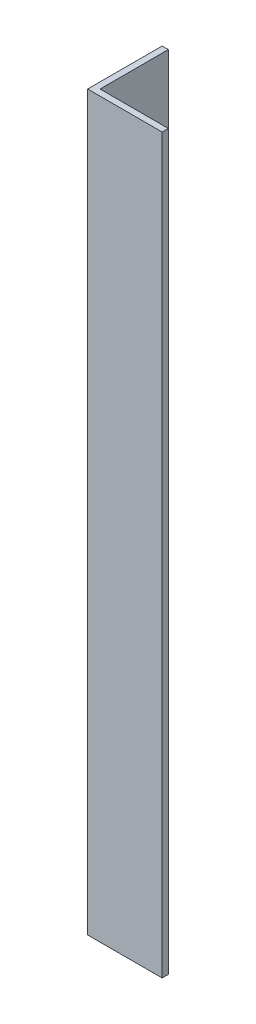
from build123d import *

# Parameters (mm, degrees)
BOSS_EXTRUDE1_DEPTH = 187.325


with BuildPart() as part:
    # Sketch1 → Boss-Extrude1 (new body)
    with BuildSketch(Plane(origin=(0, 0, 0), x_dir=(1, 0, 0), z_dir=(0, 1, 0))):
        Polygon((0, 0), (19.05, 0), (19.05, 1.5875), (1.5875, 1.5875), (1.5875, 19.05), (0, 19.05), align=None)
    extrude(amount=BOSS_EXTRUDE1_DEPTH)


solid = part.part
